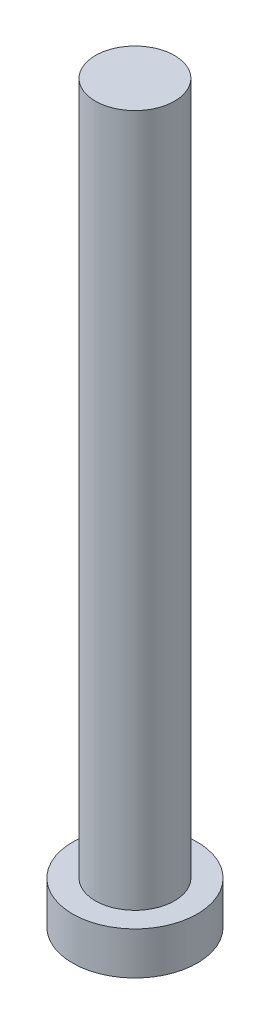
from build123d import *

# Parameters (mm, degrees)
SKETCH_1_R          = 3.15
EXTRUDE_1_DEPTH     = 2.15
SKETCH_2_R          = 2
EXTRUDE_2_DEPTH     = 35
CUT_EXTRUDE_1_DEPTH = 1.5


with BuildPart() as part:
    # 草图1 → 凸台-拉伸1 (new body)
    with BuildSketch(Plane(origin=(0, 0, 0), x_dir=(1, 0, 0), z_dir=(0, 1, 0))):
        Circle(SKETCH_1_R)
    extrude(amount=EXTRUDE_1_DEPTH)

    # 草图2 → 凸台-拉伸2 (add)
    with BuildSketch(Plane(origin=(0, 2.15, 0), x_dir=(1, 0, 0), z_dir=(0, 1, 0))):
        Circle(SKETCH_2_R)
    extrude(amount=EXTRUDE_2_DEPTH)

    # 草图3 → 切除-拉伸1 (cut)
    with BuildSketch(Plane.XZ):
        with BuildLine():
            Line((-0.5, 1), (-0.5, 2))
            Line((-0.5, 2), (0.5, 2))
            Line((0.5, 2), (0.5, 1))
            ThreePointArc((0.5, 1), (0.646446609, 0.646446609), (1, 0.5))
            Line((1, 0.5), (2, 0.5))
            Line((2, 0.5), (2, -0.5))
            Line((2, -0.5), (1, -0.5))
            ThreePointArc((1, -0.5), (0.646446609, -0.646446609), (0.5, -1))
            Line((0.5, -1), (0.5, -2))
            Line((0.5, -2), (-0.5, -2))
            Line((-0.5, -2), (-0.5, -1))
            ThreePointArc((-0.5, -1), (-0.646446609, -0.646446609), (-1, -0.5))
            Line((-1, -0.5), (-2, -0.5))
            Line((-2, -0.5), (-2, 0.5))
            Line((-2, 0.5), (-1, 0.5))
            ThreePointArc((-1, 0.5), (-0.646446609, 0.646446609), (-0.5, 1))
        make_face()
    extrude(amount=-CUT_EXTRUDE_1_DEPTH, mode=Mode.SUBTRACT)


solid = part.part
